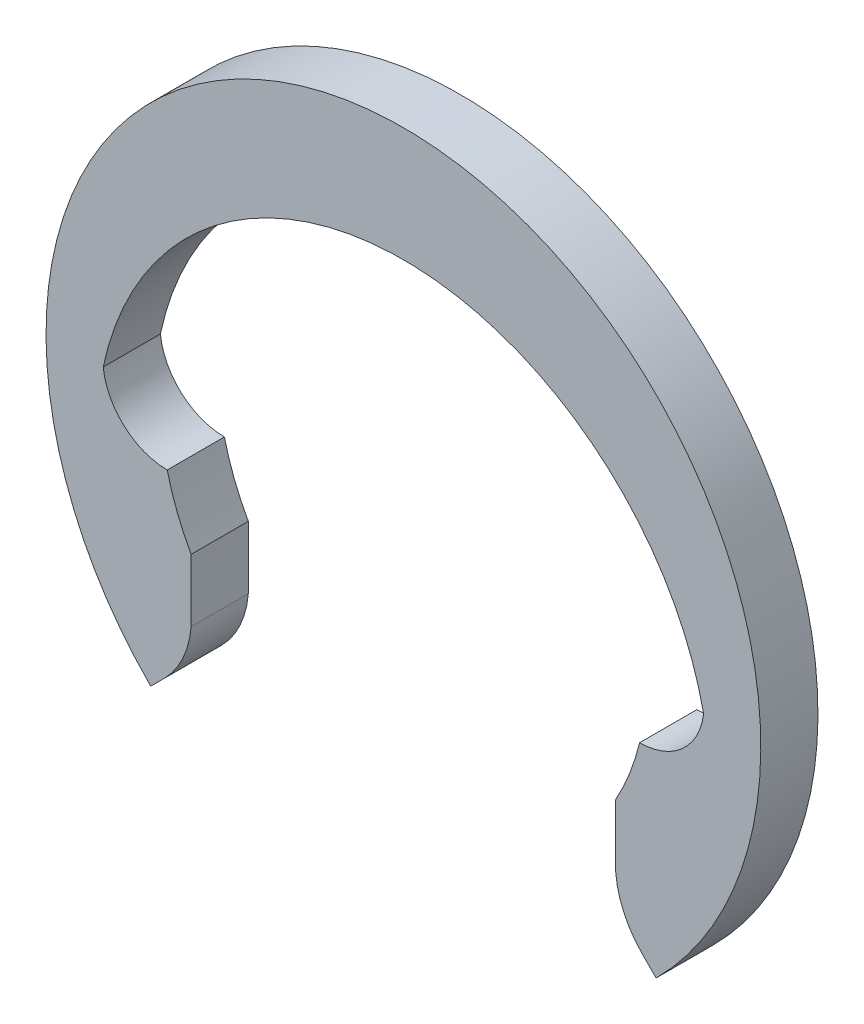
from build123d import *

# Parameters (mm, degrees)
BOSS_EXTRUDE1_DEPTH = 0.8


with BuildPart() as part:
    # Sketch2 → Boss-Extrude1 (new body)
    with BuildSketch(Plane.XY):
        with BuildLine():
            Line((-2.969848481, -2.531663833), (-2.969848481, -2.093479184))
            Line((-2.969848481, -2.093479184), (-2.969848481, -1.655294536))
            ThreePointArc((-2.969848481, -1.655294536), (-3.166208646, -1.239000729), (-3.304542328, -0.8))
            ThreePointArc((-3.304542328, -0.8), (-3.904926464, -0.570870449), (-4.2, 0))
            ThreePointArc((-4.2, 0), (0, 3.4), (4.2, 0))
            ThreePointArc((4.2, 0), (3.904926464, -0.570870449), (3.304542328, -0.8))
            ThreePointArc((3.304542328, -0.8), (3.166208646, -1.239000729), (2.969848481, -1.655294536))
            Line((2.969848481, -1.655294536), (2.969848481, -2.093479184))
            Line((2.969848481, -2.093479184), (2.969848481, -2.531663833))
            ThreePointArc((2.969848481, -2.531663833), (3.085880671, -2.972866787), (3.346972098, -3.346972098))
            Line((3.346972098, -3.346972098), (3.535533906, -3.535533906))
            ThreePointArc((3.535533906, -3.535533906), (0, 5), (-3.535533906, -3.535533906))
            Line((-3.535533906, -3.535533906), (-3.346972098, -3.346972098))
            ThreePointArc((-3.346972098, -3.346972098), (-3.085880671, -2.972866787), (-2.969848481, -2.531663833))
        make_face()
    extrude(amount=BOSS_EXTRUDE1_DEPTH)


solid = part.part
